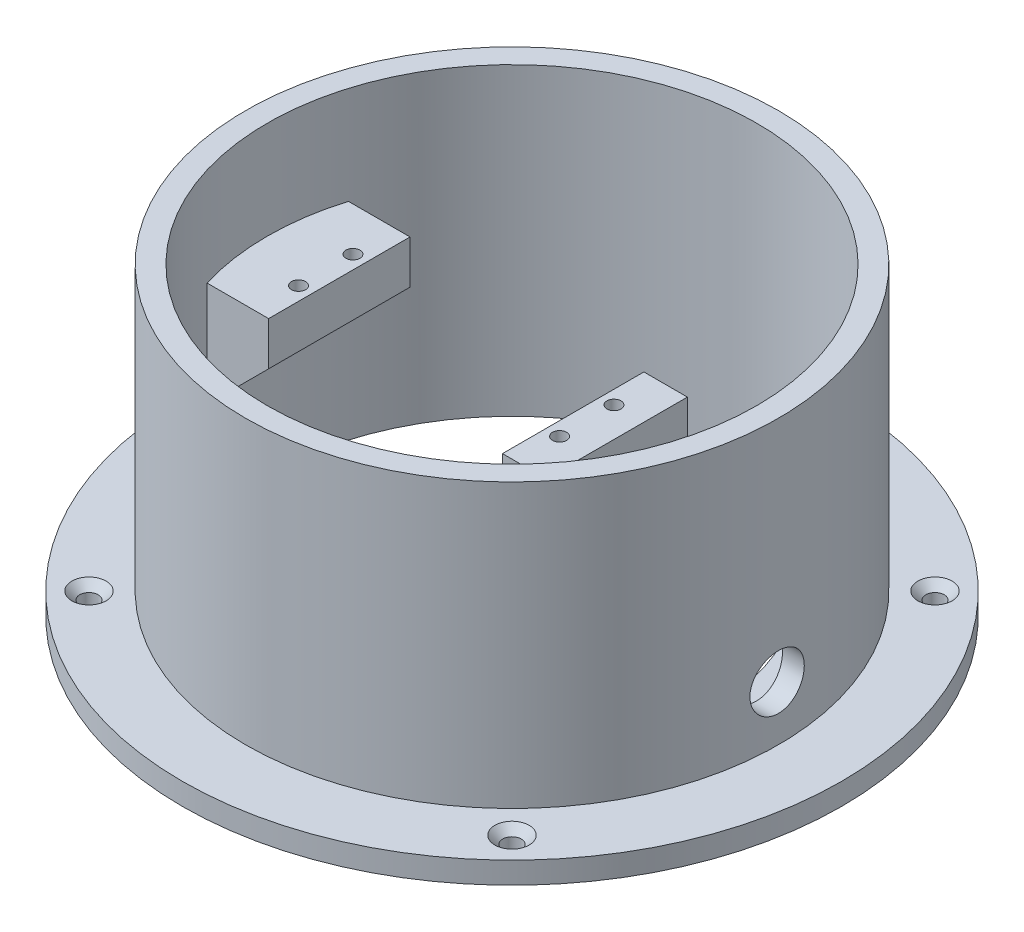
from build123d import *

# Parameters (mm, degrees)
SKETCH1_R                                           = 60.625
SKETCH1_R_2                                         = 45
BOSS_EXTRUDE1_DEPTH                                 = 4
SKETCH2_R                                           = 49
SKETCH2_R_2                                         = 45
BOSS_EXTRUDE2_DEPTH                                 = 52
SKETCH4_W                                           = 13.25
SKETCH4_H                                           = 8
SKETCH4_W_2                                         = 8
SKETCH4_H_2                                         = 38
BOSS_EXTRUDE4_DEPTH                                 = 13
BOSS_EXTRUDE5_DEPTH                                 = 4
SKETCH7_R                                           = 1.3
CUT_EXTRUDE4_DEPTH                                  = 7.2
SKETCH9_W                                           = 10
SKETCH9_H                                           = 24
CUT_EXTRUDE7_DEPTH                                  = 8
CUT_EXTRUDE8_REACH                                  = 111.625
SKETCH11_R                                          = 5
CUT_EXTRUDE9_DEPTH                                  = 5.0000001
CSK_FOR_M3_COUNTERSUNK_FLAT_HEAD_SCREW1_D           = 3.4
CSK_FOR_M3_COUNTERSUNK_FLAT_HEAD_SCREW1_DEPTH       = 4
CSK_FOR_M3_COUNTERSUNK_FLAT_HEAD_SCREW1_CSINK_D     = 6.3
CSK_FOR_M3_COUNTERSUNK_FLAT_HEAD_SCREW1_CSINK_ANGLE = 90


with BuildPart() as part:
    # Sketch1 → Boss-Extrude1 (new body)
    with BuildSketch(Plane(origin=(0, 0, 0), x_dir=(1, 0, 0), z_dir=(0, 1, 0))):
        Circle(SKETCH1_R)
        Circle(SKETCH1_R_2, mode=Mode.SUBTRACT)
    extrude(amount=BOSS_EXTRUDE1_DEPTH)

    # Sketch2 → Boss-Extrude2 (add)
    with BuildSketch(Plane(origin=(0, 4, 0), x_dir=(1, 0, 0), z_dir=(0, 1, 0))):
        Circle(SKETCH2_R)
        Circle(SKETCH2_R_2, mode=Mode.SUBTRACT)
    extrude(amount=BOSS_EXTRUDE2_DEPTH)

    # Sketch4 → Boss-Extrude4 (add, symmetric)
    with BuildSketch(Plane.XY):
        with Locations((-38.375, 34)):
            Rectangle(SKETCH4_W, SKETCH4_H)
        Polygon((-31.75, 30), (-45, 30), (-45, 16.75), align=None)
        with Locations((15.25, 19)):
            Rectangle(SKETCH4_W_2, SKETCH4_H_2)
    extrude(amount=BOSS_EXTRUDE4_DEPTH, both=True)

    # Sketch5 → Boss-Extrude5 (add)
    with BuildSketch(Plane.XZ):
        with BuildLine():
            Line((11.25, 13), (29.067400866, 34.352382842))
            ThreePointArc((29.067400866, 34.352382842), (45, 0), (29.067400866, -34.352382842))
            Line((29.067400866, -34.352382842), (11.25, -13))
            Line((11.25, -13), (11.25, 13))
        make_face()
    extrude(amount=-BOSS_EXTRUDE5_DEPTH)

    # Sketch7 → Cut-Extrude4 (cut)
    with BuildSketch(Plane(origin=(0, 38, 0), x_dir=(1, 0, 0), z_dir=(0, 1, 0))):
        with Locations((-34.25, 5)):
            Circle(SKETCH7_R)
        with Locations((-34.25, -5)):
            Circle(SKETCH7_R)
        with Locations((13.75, 5)):
            Circle(SKETCH7_R)
        with Locations((13.75, -5)):
            Circle(SKETCH7_R)
    extrude(amount=-CUT_EXTRUDE4_DEPTH, mode=Mode.SUBTRACT)

    # Sketch9 → Cut-Extrude7 (cut)
    with BuildSketch(Plane.ZY.offset(-11.25)):
        with Locations((0, 17)):
            Rectangle(SKETCH9_W, SKETCH9_H)
    extrude(amount=-CUT_EXTRUDE7_DEPTH, mode=Mode.SUBTRACT)

    # Sketch11 → Cut-Extrude8 (cut, up to next)
    with BuildSketch(Plane(origin=(49, 0, 0), x_dir=(0, 0, -1), z_dir=(1, 0, 0)), mode=Mode.PRIVATE) as cut_extrude8_sk1:
        with Locations((0, 14)):
            Circle(SKETCH11_R)
    cut_extrude8_tool1 = extrude(cut_extrude8_sk1.sketch, amount=-CUT_EXTRUDE8_REACH, mode=Mode.PRIVATE) & part.part
    add(cut_extrude8_tool1.solids().sort_by_distance((49, 14, 0))[0], mode=Mode.SUBTRACT)

    # Sketch12 → Cut-Extrude9 (cut, through all)
    with BuildSketch(Plane(origin=(0, 4, 0), x_dir=(1, 0, 0), z_dir=(0, 1, 0))):
        with BuildLine():
            Line((29.479537487, 22.359715328), (27.25, 19.687836398))
            Line((27.25, 19.687836398), (27.25, -19.687836398))
            Line((27.25, -19.687836398), (29.479537487, -22.359715328))
            ThreePointArc((29.479537487, -22.359715328), (37, 0), (29.479537487, 22.359715328))
        make_face()
        Polygon((27.25, -19.687836398), (27.25, 19.687836398), (24.25, 16.092634774), (24.25, -16.092634774), align=None)
    extrude(amount=-CUT_EXTRUDE9_DEPTH, mode=Mode.SUBTRACT)

    # CSK for M3 Countersunk Flat Head Screw1
    with Locations(Plane(origin=(0, 4, 0), x_dir=(1, 0, 0), z_dir=(0, 1, 0))):
        with Locations((-38.890872965, 38.890872965), (-38.890872965, -38.890872965), (38.890872965, -38.890872965), (38.890872965, 38.890872965)):
            CounterSinkHole(CSK_FOR_M3_COUNTERSUNK_FLAT_HEAD_SCREW1_D / 2, CSK_FOR_M3_COUNTERSUNK_FLAT_HEAD_SCREW1_CSINK_D / 2, depth=CSK_FOR_M3_COUNTERSUNK_FLAT_HEAD_SCREW1_DEPTH, counter_sink_angle=CSK_FOR_M3_COUNTERSUNK_FLAT_HEAD_SCREW1_CSINK_ANGLE)


solid = part.part
